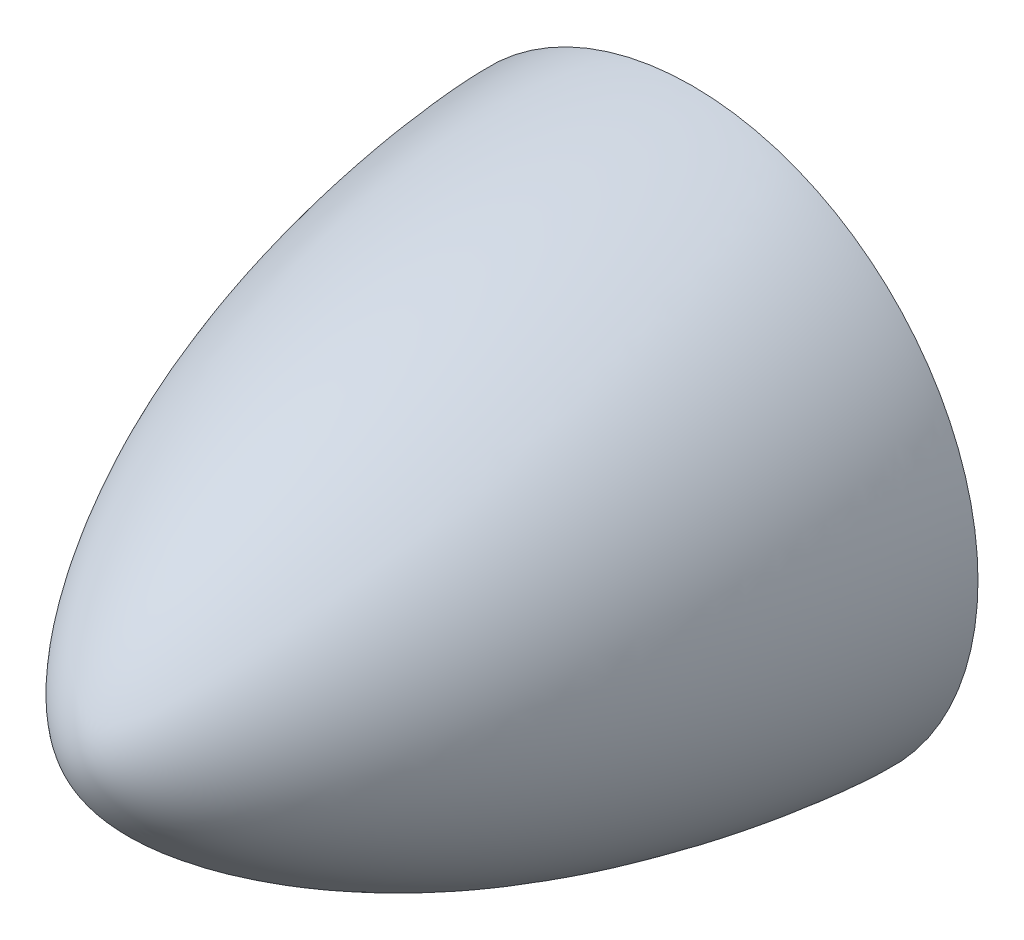
from build123d import *


with BuildPart() as part:
    # Sketch2 (on Right Plane) → Revolve1 (revolve)
    with BuildSketch(Plane(origin=(0, 0, 0), x_dir=(0, 0, -1), z_dir=(1, 0, 0))):
        with BuildLine():
            Line((0, 0), (0, 37.489748036))
            add(Edge.make_bspline(
                [(-80, 0), (-80, 8.795353718), (-45.578141912, 33.888321334), (-6.520846957, 37.489748036), (0, 37.489748036)],
                knots=[0, 0, 0, 0, 0.444533139, 1, 1, 1, 1], degree=3))
            Line((-80, 0), (0, 0))
        make_face()
    revolve(axis=Axis((0, 0, 80), (0, 0, -1)))


solid = part.part
